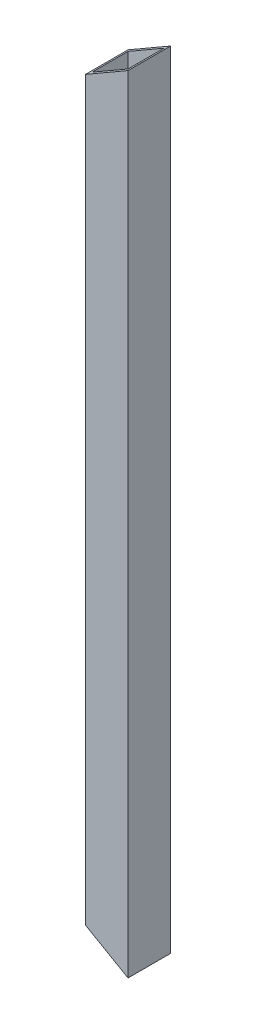
from build123d import *

# Parameters (mm, degrees)
SKETCH2_W               = 13
SKETCH2_H               = 13
SKETCH2_W_2             = 11
SKETCH2_H_2             = 11
BOSS_EXTRUDE1_DEPTH     = 240
CUT_EXTRUDE1_DEPTH      = 1
CUT_EXTRUDE1_DEPTH_BACK = 14
SKETCH4_OUTSIDE_W       = 63.14
SKETCH4_OUTSIDE_H       = 290.14
CUT_EXTRUDE2_DEPTH      = 240


with BuildPart() as part:
    # Sketch2 → Boss-Extrude1 (new body)
    with BuildSketch(Plane(origin=(0, 0, 0), x_dir=(1, 0, 0), z_dir=(0, 1, 0))):
        Rectangle(SKETCH2_W, SKETCH2_H)
        Rectangle(SKETCH2_W_2, SKETCH2_H_2, mode=Mode.SUBTRACT)
    extrude(amount=BOSS_EXTRUDE1_DEPTH)

    # Sketch3 → Cut-Extrude1 (cut, two sides)
    with BuildSketch(Plane.XY.offset(6.5)) as cut_extrude1_sk:
        Polygon((431.461827419, 485.351825456), (6.5, 240), (-6.5, 232.494446501), (-431.461827419, -12.857378955), (-922.165478331, 837.066275884), (-59.241823492, 1335.275480295), align=None)
    extrude(amount=CUT_EXTRUDE1_DEPTH, mode=Mode.SUBTRACT)
    extrude(cut_extrude1_sk.sketch, amount=-CUT_EXTRUDE1_DEPTH_BACK, mode=Mode.SUBTRACT)

    # Sketch4 outside → Cut-Extrude2 (cut)
    with BuildSketch(Plane.XY.offset(6.5)):
        with Locations((0, 120)):
            Rectangle(SKETCH4_OUTSIDE_W, SKETCH4_OUTSIDE_H)
        Polygon((6.5, 0), (-6.5, 7.505553499), (-6.5, 232.494446501), (6.5, 240), align=None, mode=Mode.SUBTRACT)
    extrude(amount=-CUT_EXTRUDE2_DEPTH, mode=Mode.SUBTRACT)


solid = part.part
